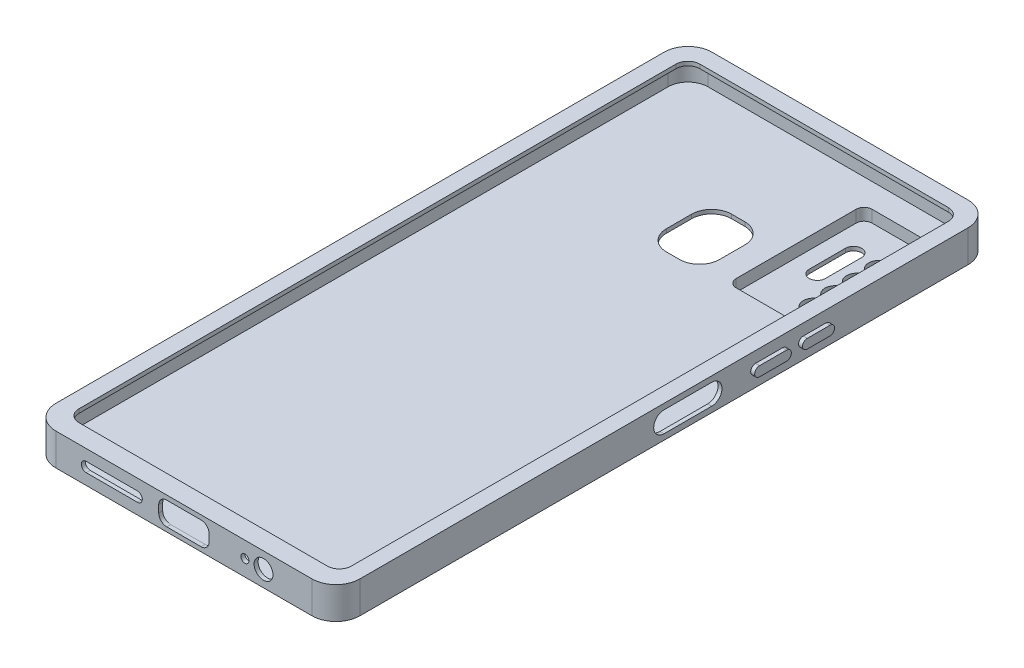
from build123d import *

# Parameters (mm, degrees)
SKETCH1_W                = 76
SKETCH1_H                = 164
BOSS_EXTRUDE1_DEPTH      = 8
FILLET1_R                = 6
SHELL1_T                 = 1
CUT_EXTRUDE1_REACH       = 10
SKETCH2_W                = 68.090837492
SKETCH2_H                = 155.209096006
FILLET2_R                = 3
SKETCH4_W                = 21.544378241
SKETCH4_H                = 36.731163213
BOSS_EXTRUDE2_DEPTH      = 4
SKETCH6_W                = 16.414160097
SKETCH6_H                = 31.306477537
CUT_EXTRUDE2_DEPTH       = 1
FILLET3_R                = 2
SKETCH8_R                = 3
BOSS_EXTRUDE4_DEPTH      = 1
SKETCH9_R                = 2.588654276
CUT_EXTRUDE3_DEPTH       = 13
CUT_EXTRUDE4_DEPTH       = 12
SKETCH11_W               = 13.306062394
SKETCH11_H               = 16.319570906
CUT_EXTRUDE5_DEPTH       = 9
FILLET4_R                = 5
SKETCH12_W               = 19
SKETCH12_H               = 34
CUT_EXTRUDE6_DEPTH       = 3
FILLET5_R                = 2
SKETCH13_R               = 1
SKETCH13_R_2             = 2.358901761
SKETCH13_W               = 12.594466328
SKETCH13_H               = 5.779421342
CUT_EXTRUDE7_DEPTH       = 3
FILLET6_R                = 2
CUT_EXTRUDE8_DEPTH       = 3
BOSS_EXTRUDE5_DEPTH      = 1
BOSS_EXTRUDE5_DEPTH_BACK = 1.05
CUT_EXTRUDE10_DEPTH      = 0.5


with BuildPart() as part:
    # Sketch1 → Boss-Extrude1 (new body)
    with BuildSketch(Plane(origin=(0, 0, 0), x_dir=(1, 0, 0), z_dir=(0, 1, 0))):
        with Locations((38, 82)):
            Rectangle(SKETCH1_W, SKETCH1_H)
    extrude(amount=BOSS_EXTRUDE1_DEPTH)

    # Fillet1
    fillet1_edges = [part.edges().sort_by_distance(p)[0] for p in [
        (0, 4, -164),
        (76, 4, -164),
        (76, 4, 0),
        (0, 4, 0),
    ]]
    fillet(fillet1_edges, radius=FILLET1_R)

    # Shell1 (no face opened: a closed hollow body)
    add(offset(amount=-SHELL1_T, mode=Mode.PRIVATE), mode=Mode.SUBTRACT)

    # Sketch2 → Cut-Extrude1 (cut, up to next)
    with BuildSketch(Plane(origin=(0, 8, 0), x_dir=(1, 0, 0), z_dir=(0, 1, 0)), mode=Mode.PRIVATE) as cut_extrude1_sk1:
        with Locations((38.110048525, 82.297833248)):
            Rectangle(SKETCH2_W, SKETCH2_H)
    cut_extrude1_tool1 = extrude(cut_extrude1_sk1.sketch, amount=-CUT_EXTRUDE1_REACH, mode=Mode.PRIVATE) & part.part
    add(cut_extrude1_tool1.solids().sort_by_distance((38.110049, 8, -82.297833))[0], mode=Mode.SUBTRACT)

    # Fillet2
    fillet2_edges = [part.edges().sort_by_distance(p)[0] for p in [
        (4.064629779, 7.5, -4.693285245),
        (4.064629779, 7.5, -159.902381251),
        (72.155467271, 7.5, -159.902381251),
        (72.155467271, 7.5, -4.693285245),
    ]]
    fillet(fillet2_edges, radius=FILLET2_R)

    # Sketch4 → Boss-Extrude2 (add)
    with BuildSketch(Plane.XZ):
        with Locations((60.564172536, -139.655463134)):
            Rectangle(SKETCH4_W, SKETCH4_H)
    extrude(amount=BOSS_EXTRUDE2_DEPTH)

    # Sketch6 → Cut-Extrude2 (cut)
    with BuildSketch(Plane.XZ.offset(4)):
        with Locations((60.620345212, -139.734289673)):
            Rectangle(SKETCH6_W, SKETCH6_H)
    extrude(amount=-CUT_EXTRUDE2_DEPTH, mode=Mode.SUBTRACT)

    # Fillet3
    fillet3_edges = [part.edges().sort_by_distance(p)[0] for p in [
        (52.413265163, -3.5, -155.387528441),
        (52.413265163, -3.5, -124.081050904),
        (68.82742526, -3.5, -124.081050904),
        (68.82742526, -3.5, -155.387528441),
        (49.791983416, -2, -158.021044741),
        (71.336361657, -2, -158.021044741),
        (71.336361657, -2, -121.289881528),
        (49.791983416, -2, -121.289881528),
    ]]
    fillet(fillet3_edges, radius=FILLET3_R)

    # Sketch8 → Boss-Extrude4 (add)
    with BuildSketch(Plane.XZ.offset(3)):
        with Locations((63.775573367, -131.698200541)):
            Circle(SKETCH8_R)
        with Locations((63.775573367, -137.083152025)):
            Circle(SKETCH8_R)
        with Locations((63.775573367, -142.468103509)):
            Circle(SKETCH8_R)
        with Locations((63.775573367, -147.927845985)):
            Circle(SKETCH8_R)
    extrude(amount=BOSS_EXTRUDE4_DEPTH)

    # Sketch9 → Cut-Extrude3 (cut, through all)
    with BuildSketch(Plane.XZ.offset(4)):
        with Locations((63.763440022, -131.636981019)):
            Circle(SKETCH9_R)
        with Locations((63.763440022, -137.042310835)):
            Circle(SKETCH9_R)
        with Locations((63.763440022, -142.459827466)):
            Circle(SKETCH9_R)
        with Locations((63.763440022, -147.953993096)):
            Circle(SKETCH9_R)
    extrude(amount=-CUT_EXTRUDE3_DEPTH, mode=Mode.SUBTRACT)

    # Sketch10 → Cut-Extrude4 (cut, through all)
    with BuildSketch(Plane.XZ.offset(3)):
        with BuildLine():
            Line((55.113000289, -148.242856688), (55.113000289, -139.17331968))
            ThreePointArc((55.113000289, -139.17331968), (57.128452957, -137.157867012), (59.143905626, -139.17331968))
            Line((59.143905626, -139.17331968), (59.143905626, -148.242856688))
            ThreePointArc((59.143905626, -148.242856688), (57.128452957, -150.258309356), (55.113000289, -148.242856688))
        make_face()
    extrude(amount=-CUT_EXTRUDE4_DEPTH, mode=Mode.SUBTRACT)

    # Sketch11 → Cut-Extrude5 (cut, through all)
    with BuildSketch(Plane.XZ):
        with Locations((38.157494148, -130.226713283)):
            Rectangle(SKETCH11_W, SKETCH11_H)
    extrude(amount=-CUT_EXTRUDE5_DEPTH, mode=Mode.SUBTRACT)

    # Fillet4
    fillet4_edges = [part.edges().sort_by_distance(p)[0] for p in [
        (44.810525345, 0.5, -122.06692783),
        (44.810525345, 0.5, -138.386498736),
        (31.504462951, 0.5, -138.386498736),
        (31.504462951, 0.5, -122.06692783),
    ]]
    fillet(fillet4_edges, radius=FILLET4_R)

    # Sketch12 → Cut-Extrude6 (cut)
    with BuildSketch(Plane(origin=(0, 1, 0), x_dir=(1, 0, 0), z_dir=(0, 1, 0))):
        with Locations((60.5, 140)):
            Rectangle(SKETCH12_W, SKETCH12_H)
    extrude(amount=-CUT_EXTRUDE6_DEPTH, mode=Mode.SUBTRACT)

    # Fillet5
    fillet5_edges = [part.edges().sort_by_distance(p)[0] for p in [
        (51, -0.5, -123),
        (51, -0.5, -157),
        (70, -0.5, -157),
        (70, -0.5, -123),
    ]]
    fillet(fillet5_edges, radius=FILLET5_R)

    # Sketch13 → Cut-Extrude7 (cut)
    with BuildSketch(Plane.XY):
        with Locations((53.247860204, 4)):
            Circle(SKETCH13_R)
        with Locations((57.897972679, 4)):
            Circle(SKETCH13_R_2)
        with Locations((38, 4)):
            Rectangle(SKETCH13_W, SKETCH13_H)
        with BuildLine():
            Line((13.587580426, 5.22660483), (26.376302174, 5.22660483))
            ThreePointArc((26.376302174, 5.22660483), (27.602907004, 4), (26.376302174, 2.77339517))
            Line((26.376302174, 2.77339517), (13.587580426, 2.77339517))
            ThreePointArc((13.587580426, 2.77339517), (12.360975595, 4), (13.587580426, 5.22660483))
        make_face()
    extrude(amount=-CUT_EXTRUDE7_DEPTH, mode=Mode.SUBTRACT)

    # Fillet6
    fillet6_edges = [part.edges().sort_by_distance(p)[0] for p in [
        (44.297233164, 6.889710671, -0.5),
        (44.297233164, 1.110289329, -0.5),
        (31.702766836, 1.110289329, -0.5),
        (31.702766836, 6.889710671, -0.5),
    ]]
    fillet(fillet6_edges, radius=FILLET6_R)

    # Sketch14 → Cut-Extrude8 (cut)
    with BuildSketch(Plane(origin=(76, 0, 0), x_dir=(0, 0, -1), z_dir=(1, 0, 0))):
        with BuildLine():
            Line((82, 6.583142287), (93.908604514, 6.583142287))
            ThreePointArc((93.908604514, 6.583142287), (96.491746801, 4), (93.908604514, 1.416857713))
            Line((93.908604514, 1.416857713), (82, 1.416857713))
            ThreePointArc((82, 1.416857713), (79.416857713, 4), (82, 6.583142287))
        make_face()
    extrude(amount=-CUT_EXTRUDE8_DEPTH, mode=Mode.SUBTRACT)

    # Sketch16 → Boss-Extrude5 (add, two sides)
    with BuildSketch(Plane(origin=(76, 0, 0), x_dir=(0, 0, -1), z_dir=(1, 0, 0))) as boss_extrude5_sk:
        with BuildLine():
            Line((104.869041793, 5.208410876), (111.609162215, 5.208410876))
            ThreePointArc((111.609162215, 5.208410876), (112.817573091, 4), (111.609162215, 2.791589124))
            Line((111.609162215, 2.791589124), (104.869041793, 2.791589124))
            ThreePointArc((104.869041793, 2.791589124), (103.660630917, 4), (104.869041793, 5.208410876))
        make_face()
        with BuildLine():
            Line((116.772794214, 5.160242941), (122.470244074, 5.160242941))
            ThreePointArc((122.470244074, 5.160242941), (123.630487014, 4), (122.470244074, 2.839757059))
            Line((122.470244074, 2.839757059), (116.772794214, 2.839757059))
            ThreePointArc((116.772794214, 2.839757059), (115.612551274, 4), (116.772794214, 5.160242941))
        make_face()
    extrude(amount=BOSS_EXTRUDE5_DEPTH)
    extrude(boss_extrude5_sk.sketch, amount=-BOSS_EXTRUDE5_DEPTH_BACK)

    # Sketch18 → Cut-Extrude10 (cut)
    with BuildSketch(Plane.ZY.offset(-75)):
        with BuildLine():
            Line((-125.166067696, 6.347699062), (-101.524019083, 6.347699062))
            ThreePointArc((-101.524019083, 6.347699062), (-99.246881257, 4.070561235), (-101.524019083, 1.793423409))
            Line((-101.524019083, 1.793423409), (-125.166067696, 1.793423409))
            ThreePointArc((-125.166067696, 1.793423409), (-127.443205522, 4.070561235), (-125.166067696, 6.347699062))
        make_face()
    extrude(amount=-CUT_EXTRUDE10_DEPTH, mode=Mode.SUBTRACT)


solid = part.part
